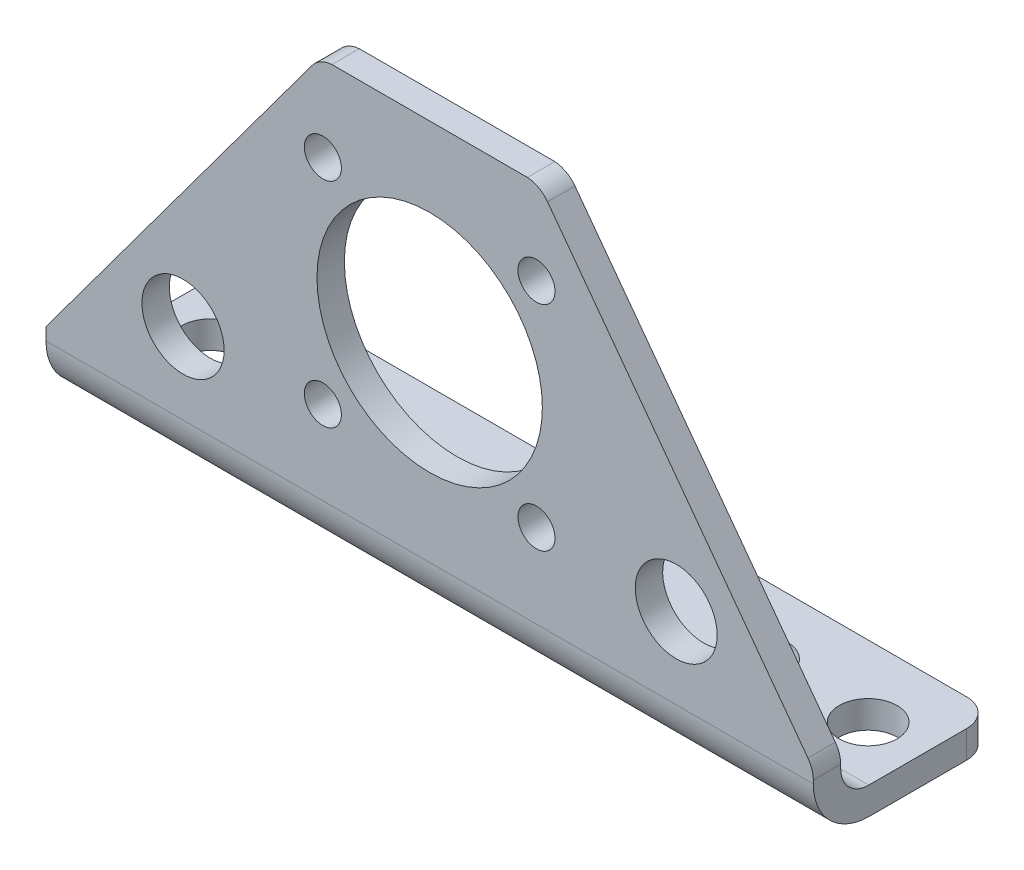
from build123d import *

# Parameters (mm, degrees)
BOSS_EXTRUDE1_DEPTH = 44.45
SKETCH2_OUTSIDE_W   = 111.802
SKETCH2_OUTSIDE_H   = 43.857
SKETCH2_OUTSIDE_R   = 3.3528
SKETCH2_OUTSIDE_R_2 = 6.35
CUT_EXTRUDE3_DEPTH  = 51.8
SKETCH3_OUTSIDE_W   = 111.802
SKETCH3_OUTSIDE_H   = 73.702
SKETCH3_OUTSIDE_R   = 2.1463
SKETCH3_OUTSIDE_R_2 = 13.0556
SKETCH3_OUTSIDE_R_3 = 4.7625
SKETCH3_OUTSIDE_R_4 = 4.743651166
CUT_EXTRUDE4_DEPTH  = 21.948744152


with BuildPart() as part:
    # Sketch1 → Boss-Extrude1 (new body, symmetric)
    with BuildSketch(Plane.ZY):
        with BuildLine():
            Line((-20.955, -28.575), (-6.5, -28.575))
            ThreePointArc((-6.5, -28.575), (-1.903805922, -26.671194078), (0, -22.075))
            Line((0, -22.075), (0, 22.225))
            Line((0, 22.225), (-3.175, 22.225))
            Line((-3.175, 22.225), (-3.175, -22.15))
            ThreePointArc((-3.175, -22.15), (-4.126902961, -24.448097039), (-6.425, -25.4))
            Line((-6.425, -25.4), (-20.955, -25.4))
            Line((-20.955, -25.4), (-20.955, -28.575))
        make_face()
    extrude(amount=BOSS_EXTRUDE1_DEPTH, both=True)

    # Sketch2 outside → Cut-Extrude3 (cut, through all)
    with BuildSketch(Plane.XZ.offset(28.575)):
        with Locations((0, -10.4775)):
            Rectangle(SKETCH2_OUTSIDE_W, SKETCH2_OUTSIDE_H)
        with BuildLine():
            Line((-41.280304188, -20.948744152), (41.275, -20.948744152))
            ThreePointArc((41.275, -20.948744152), (43.52006403, -20.018808183), (44.45, -17.773744152))
            Line((44.45, -17.773744152), (44.45, 4.535349672))
            Line((44.45, 4.535349672), (-44.455304188, 4.535349672))
            Line((-44.455304188, 4.535349672), (-44.455304188, -17.773744152))
            ThreePointArc((-44.455304188, -17.773744152), (-43.525368218, -20.018808183), (-41.280304188, -20.948744152))
        make_face(mode=Mode.SUBTRACT)
        with Locations((-38.1, -12.7)):
            Circle(SKETCH2_OUTSIDE_R)
        with Locations((-25.4, -12.7)):
            Circle(SKETCH2_OUTSIDE_R)
        with Locations((0, -12.7)):
            Circle(SKETCH2_OUTSIDE_R_2)
        with Locations((25.4, -12.7)):
            Circle(SKETCH2_OUTSIDE_R)
        with Locations((38.1, -12.7)):
            Circle(SKETCH2_OUTSIDE_R)
    extrude(amount=-CUT_EXTRUDE3_DEPTH, mode=Mode.SUBTRACT)

    # Sketch3 outside → Cut-Extrude4 (cut, through all)
    with BuildSketch(Plane.XY):
        with Locations((0, -3.175)):
            Rectangle(SKETCH3_OUTSIDE_W, SKETCH3_OUTSIDE_H)
        with BuildLine():
            Line((-13.653876698, 20.947210396), (-44.450826739, -20.631729198))
            Line((-44.450826739, -20.631729198), (-44.450826739, -28.575))
            Line((-44.450826739, -28.575), (44.45, -28.575))
            Line((44.45, -28.575), (44.45, -21.674369393))
            ThreePointArc((44.45, -21.674369393), (44.29004015, -20.679302615), (43.826278492, -19.784500865))
            Line((43.826278492, -19.784500865), (13.654037866, 20.947321174))
            ThreePointArc((13.654037866, 20.947321174), (12.531096243, 21.893026448), (11.102759374, 22.232452646))
            Line((11.102759374, 22.232452646), (-11.10251615, 22.232452646))
            ThreePointArc((-11.10251615, 22.232452646), (-12.530914579, 21.892995438), (-13.653876698, 20.947210396))
        make_face(mode=Mode.SUBTRACT)
        with Locations((-12.374792935, 12.374792935)):
            Circle(SKETCH3_OUTSIDE_R)
        with Locations((12.374792935, 12.374792935)):
            Circle(SKETCH3_OUTSIDE_R)
        Circle(SKETCH3_OUTSIDE_R_2)
        with Locations((-28.575, -12.7)):
            Circle(SKETCH3_OUTSIDE_R_3)
        with Locations((-12.374792935, -12.374792935)):
            Circle(SKETCH3_OUTSIDE_R)
        with Locations((12.374792935, -12.374792935)):
            Circle(SKETCH3_OUTSIDE_R)
        with Locations((28.564780042, -12.715837646)):
            Circle(SKETCH3_OUTSIDE_R_4)
    extrude(amount=-CUT_EXTRUDE4_DEPTH, mode=Mode.SUBTRACT)


solid = part.part
